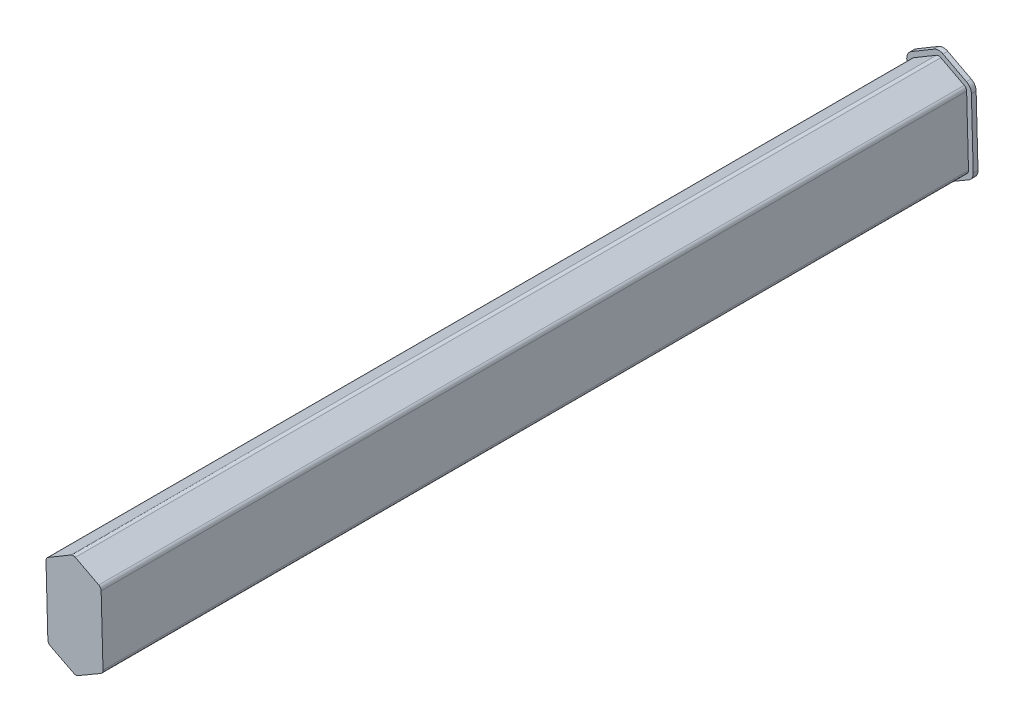
from build123d import *

# Parameters (mm, degrees)
BOSS_EXTRUDE1_DEPTH = 182
BOSS_EXTRUDE2_DEPTH = 1


with BuildPart() as part:
    # Sketch1 → Boss-Extrude1 (new body)
    with BuildSketch(Plane.XY):
        with BuildLine():
            Line((229.466385633, 190.084774284), (234.388449239, 187.516604015))
            ThreePointArc((234.388449239, 187.516604015), (234.754582519, 187.177871366), (234.898637882, 186.70033452))
            Line((234.898637882, 186.70033452), (235.288181443, 172.459456354))
            ThreePointArc((235.288181443, 172.459456354), (235.168635365, 171.971488379), (234.816933894, 171.612726503))
            Line((234.816933894, 171.612726503), (230.041262707, 168.829103536))
            ThreePointArc((230.041262707, 168.829103536), (229.588841957, 168.700212112), (229.130051641, 168.80417836))
            Line((229.130051641, 168.80417836), (224.209349738, 171.322567703))
            ThreePointArc((224.209349738, 171.322567703), (223.838561786, 171.661566677), (223.692518777, 172.142269754))
            Line((223.692518777, 172.142269754), (223.302975216, 186.383147919))
            ThreePointArc((223.302975216, 186.383147919), (223.420709707, 186.867845739), (223.767778026, 187.226087233))
            Line((223.767778026, 187.226087233), (228.542087512, 190.059491125))
            ThreePointArc((228.542087512, 190.059491125), (229.000953, 190.192173087), (229.466385633, 190.084774284))
        make_face()
    extrude(amount=BOSS_EXTRUDE1_DEPTH)

    # Sketch5 → Boss-Extrude2 (add)
    with BuildSketch(Plane(origin=(0, 0, 0), x_dir=(-1, 0, 0), z_dir=(0, 0, -1))):
        with BuildLine():
            Line((-229.928971048, 190.971349003), (-234.851034654, 188.403178734))
            ThreePointArc((-234.851034654, 188.403178734), (-235.602571388, 187.707885402), (-235.898263974, 186.727678192))
            Line((-235.898263974, 186.727678192), (-236.287807535, 172.486800026))
            ThreePointArc((-236.287807535, 172.486800026), (-236.04242348, 171.485181553), (-235.320509935, 170.748775595))
            Line((-235.320509935, 170.748775595), (-230.544838748, 167.965152629))
            ThreePointArc((-230.544838748, 167.965152629), (-229.616185629, 167.70058602), (-228.67445814, 167.913990424))
            Line((-228.67445814, 167.913990424), (-223.753756236, 170.432379767))
            ThreePointArc((-223.753756236, 170.432379767), (-222.992665178, 171.128219765), (-222.692892685, 172.114926081))
            Line((-222.692892685, 172.114926081), (-222.303349124, 186.355804247))
            ThreePointArc((-222.303349124, 186.355804247), (-222.545014659, 187.350710298), (-223.257418051, 188.086048102))
            Line((-223.257418051, 188.086048102), (-228.031727536, 190.919451994))
            ThreePointArc((-228.031727536, 190.919451994), (-228.973609327, 191.191799179), (-229.928971048, 190.971349003))
        make_face()
    extrude(amount=BOSS_EXTRUDE2_DEPTH)


solid = part.part
